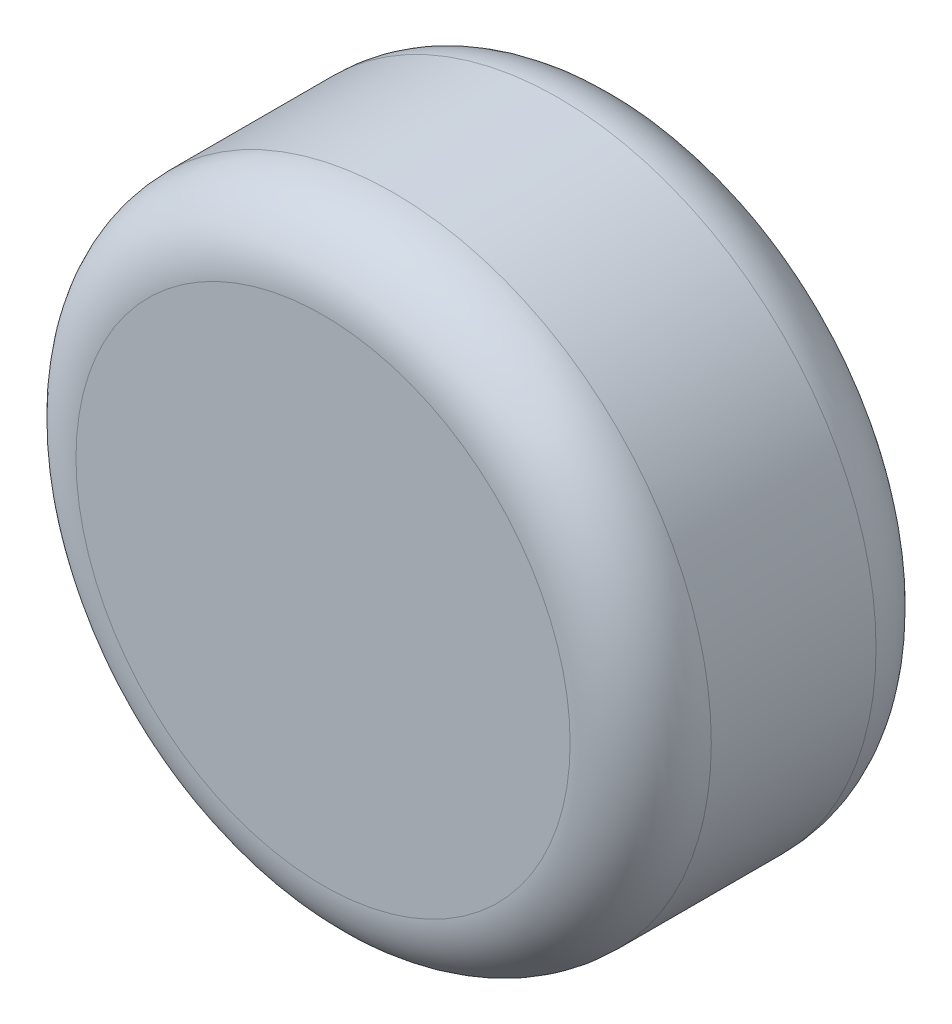
from build123d import *

# Parameters (mm, degrees)
ESQUISSE1_R        = 67.5
BOSS_EXTRU_1_DEPTH = 65
CONG_1_R           = 15


with BuildPart() as part:
    # Esquisse1 → Boss.-Extru.1 (new body)
    with BuildSketch(Plane.XY):
        Circle(ESQUISSE1_R)
    extrude(amount=BOSS_EXTRU_1_DEPTH)

    # Congé1
    cong_1_edges = [part.edges().sort_by_distance(p)[0] for p in [
        (-67.5, 0, 0),
        (-67.5, 0, 65),
    ]]
    fillet(cong_1_edges, radius=CONG_1_R)


solid = part.part
